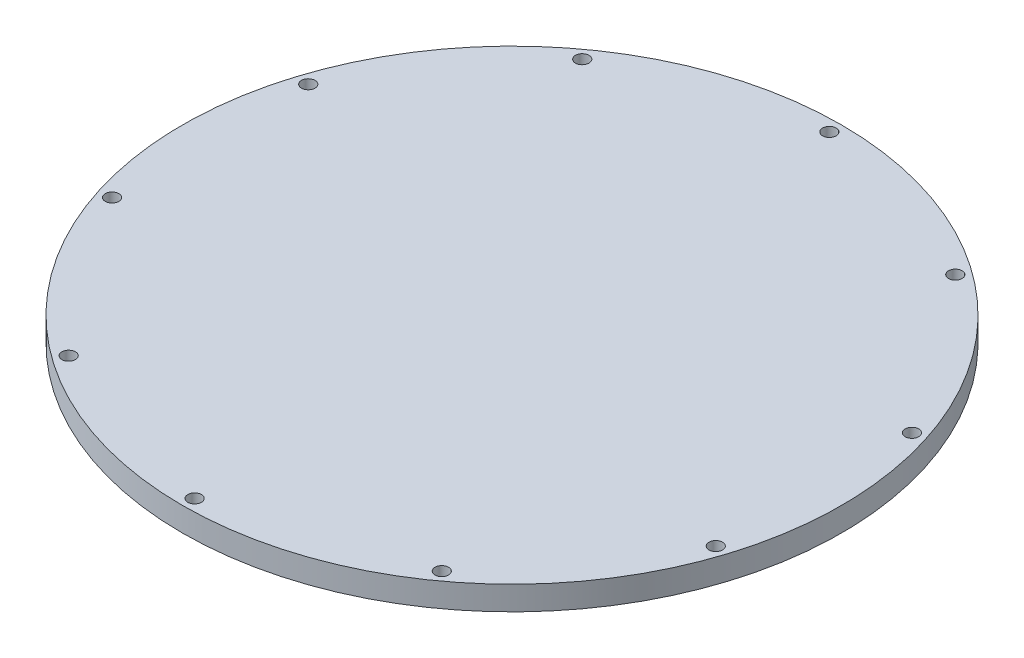
from build123d import *

# Parameters (mm, degrees)
SKETCH1_R            = 82.55
BOSS_EXTRUDE1_DEPTH  = 3
M3_CLEARANCE_HOLE1_D = 3.4


with BuildPart() as part:
    # Sketch1 → Boss-Extrude1 (new body, symmetric)
    with BuildSketch(Plane(origin=(0, 0, 0), x_dir=(1, 0, 0), z_dir=(0, 1, 0))):
        Circle(SKETCH1_R)
    extrude(amount=BOSS_EXTRUDE1_DEPTH, both=True)

    # M3 Clearance Hole1 (through all)
    with Locations(Plane(origin=(0, 3, 0), x_dir=(1, 0, 0), z_dir=(0, 1, 0))):
        with Locations((0, 79.5), (46.728927557, 64.316851053), (75.608993045, 24.566851053), (75.608993045, -24.566851053), (46.728927557, -64.316851053), (0, -79.5), (-46.728927557, -64.316851053), (-75.608993045, -24.566851053), (-75.608993045, 24.566851053), (-46.728927557, 64.316851053)):
            Hole(M3_CLEARANCE_HOLE1_D / 2)


solid = part.part
